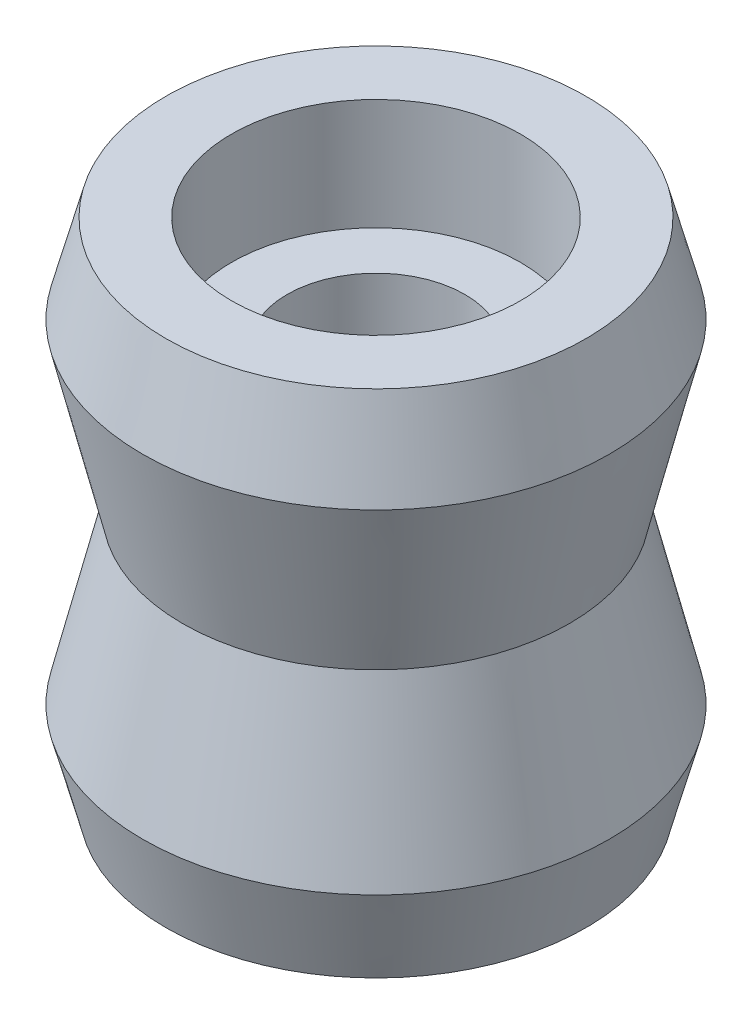
from build123d import *

# Parameters (mm, degrees)
SKETCH2_R           = 4
BOSS_EXTRUDE1_DEPTH = 0.2


with BuildPart() as part:
    # Sketch1 → Revolve1 (revolve)
    with BuildSketch(Plane.XY):
        Polygon((4, -3.284366974), (4, 9.669000537), (6.5, 9.669000537), (6.5, 14.669000537), (9.448345124, 14.669000537), (10.5, 10.692316782), (8.7, 3.192316782), (10.5, -4.307683218), (9.448345124, -8.284366974), (6.5, -8.284366974), (6.5, -3.284366974), align=None)
    revolve(axis=Axis((0, 42.323455848, 0), (0, -1, 0)))

    # Sketch2 → Boss-Extrude1 (add)
    with BuildSketch(Plane.XZ.offset(3.284366974)):
        Circle(SKETCH2_R)
    extrude(amount=-BOSS_EXTRUDE1_DEPTH)


solid = part.part
